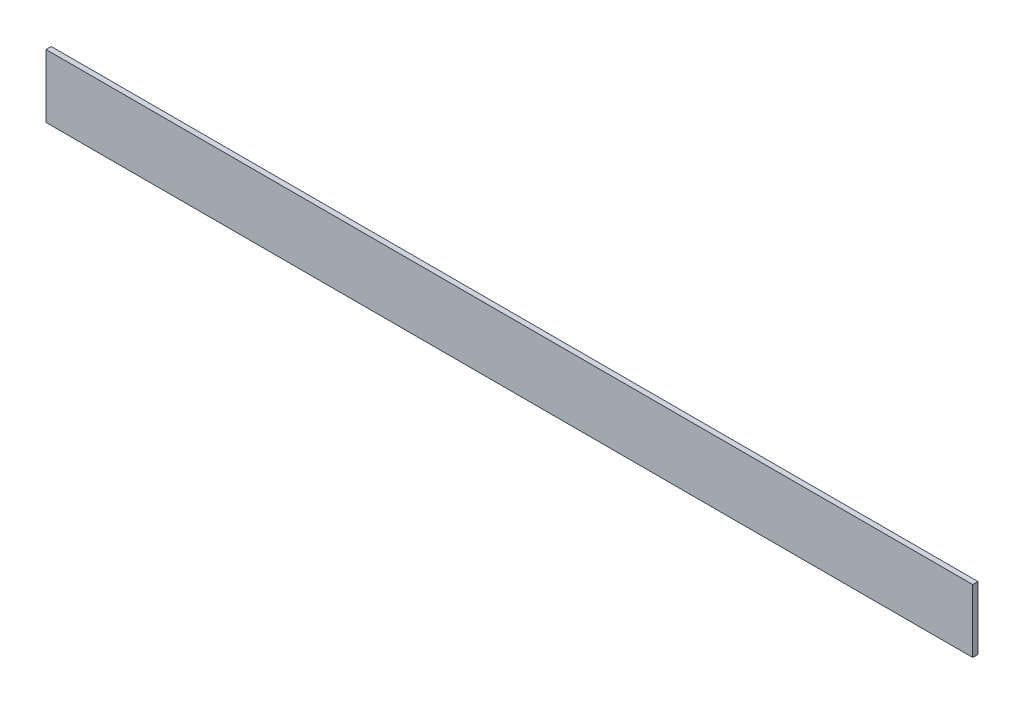
from build123d import *

# Parameters (mm, degrees)
SKETCH1_W           = 6.35
SKETCH1_H           = 76.2
BOSS_EXTRUDE1_DEPTH = 1117.6


with BuildPart() as part:
    # Sketch1 → Boss-Extrude1 (new body)
    with BuildSketch(Plane(origin=(0, 0, 0), x_dir=(0, 0, -1), z_dir=(1, 0, 0))):
        Rectangle(SKETCH1_W, SKETCH1_H)
    extrude(amount=BOSS_EXTRUDE1_DEPTH)


solid = part.part
